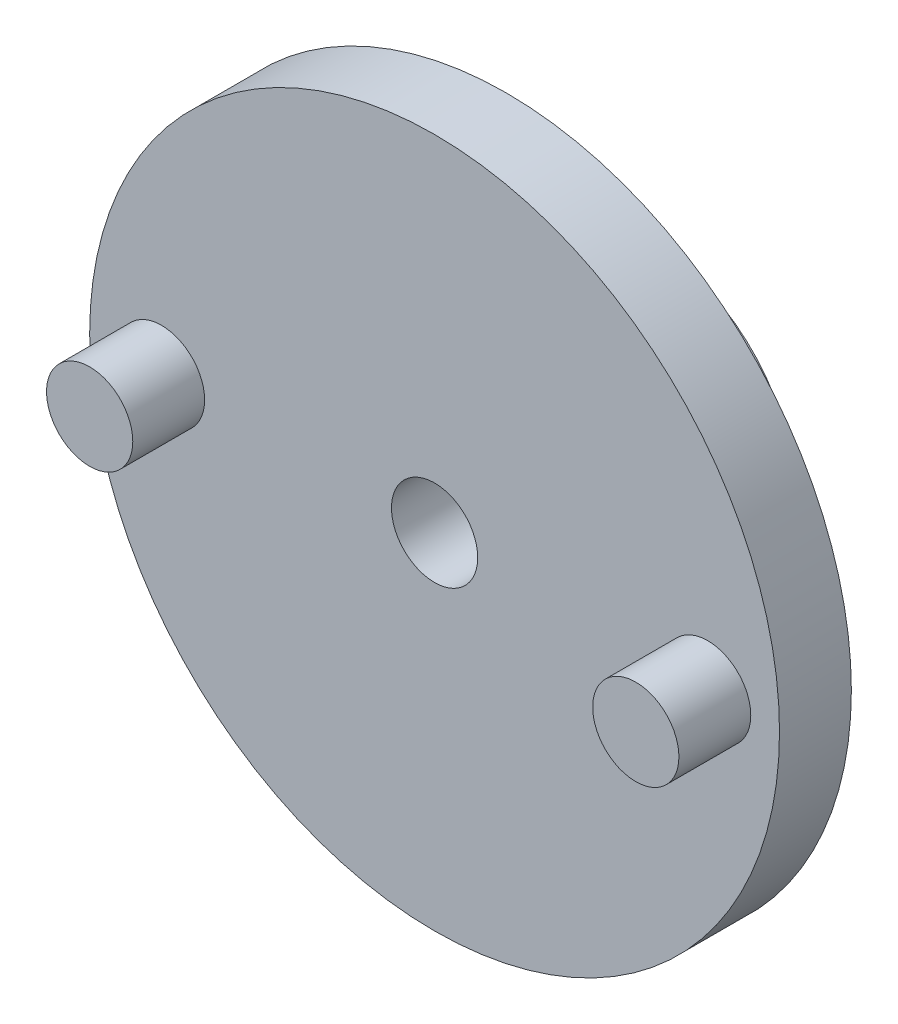
from build123d import *

# Parameters (mm, degrees)
CROQUIS1_R              = 12
SALIENTE_EXTRUIR1_DEPTH = 2.5
CROQUIS2_R              = 5
SALIENTE_EXTRUIR2_DEPTH = 5
CROQUIS3_R              = 3.1
CORTAR_EXTRUIR1_DEPTH   = 4.2
CROQUIS4_R              = 1.5
CORTAR_EXTRUIR2_DEPTH   = 4
CROQUIS5_R              = 1.5
SALIENTE_EXTRUIR3_DEPTH = 2.5
CROQUIS6_R              = 0.75
CORTAR_EXTRUIR3_DEPTH   = 2


with BuildPart() as part:
    # Croquis1 → Saliente-Extruir1 (new body)
    with BuildSketch(Plane.XY):
        Circle(CROQUIS1_R)
    extrude(amount=SALIENTE_EXTRUIR1_DEPTH)

    # Croquis2 → Saliente-Extruir2 (add)
    with BuildSketch(Plane(origin=(0, 0, 0), x_dir=(-1, 0, 0), z_dir=(0, 0, -1))):
        Circle(CROQUIS2_R)
    extrude(amount=SALIENTE_EXTRUIR2_DEPTH)

    # Croquis3 → Cortar-Extruir1 (cut)
    with BuildSketch(Plane(origin=(0, 0, -5), x_dir=(-1, 0, 0), z_dir=(0, 0, -1))):
        Circle(CROQUIS3_R)
    extrude(amount=-CORTAR_EXTRUIR1_DEPTH, mode=Mode.SUBTRACT)

    # Croquis4 → Cortar-Extruir2 (cut)
    with BuildSketch(Plane.XY.offset(2.5)):
        Circle(CROQUIS4_R)
    extrude(amount=-CORTAR_EXTRUIR2_DEPTH, mode=Mode.SUBTRACT)

    # Croquis5 → Saliente-Extruir3 (add)
    with BuildSketch(Plane.XY.offset(2.5)):
        with Locations((9.5, 0)):
            Circle(CROQUIS5_R)
        with Locations((-9.5, 0)):
            Circle(CROQUIS5_R)
    extrude(amount=SALIENTE_EXTRUIR3_DEPTH)

    # Croquis6 → Cortar-Extruir3 (cut)
    with BuildSketch(Plane(origin=(0, 0, 0), x_dir=(-1, 0, 0), z_dir=(0, 0, -1))):
        with Locations((-9.5, 0)):
            Circle(CROQUIS6_R)
        with Locations((9.5, 0)):
            Circle(CROQUIS6_R)
    extrude(amount=-CORTAR_EXTRUIR3_DEPTH, mode=Mode.SUBTRACT)


solid = part.part
